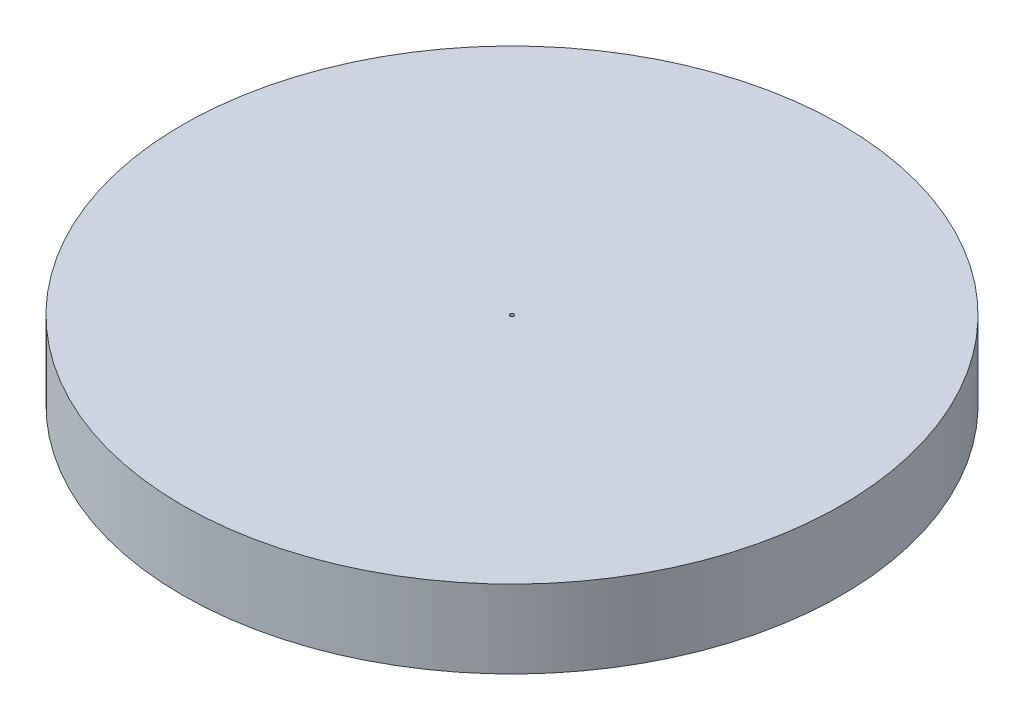
from build123d import *

# Parameters (mm, degrees)
SKETCH1_R           = 12.7
SKETCH1_R_2         = 0.075
BOSS_EXTRUDE1_DEPTH = 3


with BuildPart() as part:
    # Sketch1 → Boss-Extrude1 (new body)
    with BuildSketch(Plane(origin=(0, 0, 0), x_dir=(1, 0, 0), z_dir=(0, 1, 0))):
        Circle(SKETCH1_R)
        Circle(SKETCH1_R_2, mode=Mode.SUBTRACT)
    extrude(amount=BOSS_EXTRUDE1_DEPTH)


solid = part.part
